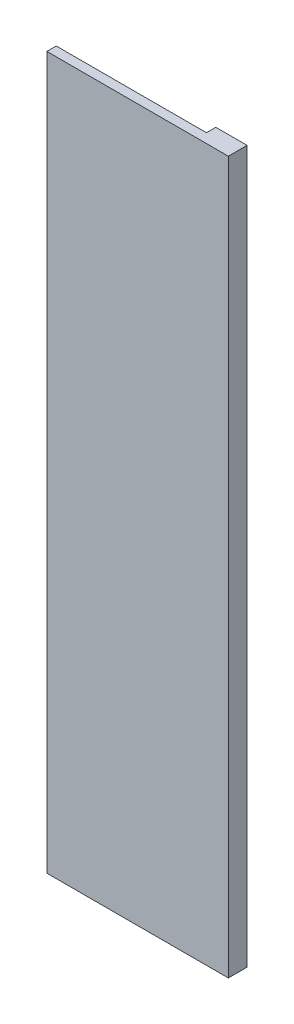
from build123d import *

# Parameters (mm, degrees)
BOSS_EXTRUDE1_DEPTH = 6
SKETCH2_W           = 116
SKETCH2_H           = 455
BOSS_EXTRUDE2_DEPTH = 6
SKETCH3_R           = 10
CUT_EXTRUDE1_DEPTH  = 6


with BuildPart() as part:
    # Sketch1 → Boss-Extrude1 (new body)
    with BuildSketch(Plane.XY):
        Polygon((68, 435), (48, 435), (48, 0), (-48, 0), (-48, -20), (68, -20), align=None)
    extrude(amount=-BOSS_EXTRUDE1_DEPTH)

    # Sketch2 → Boss-Extrude2 (add)
    with BuildSketch(Plane.XY):
        with Locations((10, 207.5)):
            Rectangle(SKETCH2_W, SKETCH2_H)
    extrude(amount=BOSS_EXTRUDE2_DEPTH)

    # Sketch3 → Cut-Extrude1 (cut)
    with BuildSketch(Plane(origin=(0, 0, -6), x_dir=(-1, 0, 0), z_dir=(0, 0, -1))):
        with Locations((-48, 0)):
            Circle(SKETCH3_R)
    extrude(amount=-CUT_EXTRUDE1_DEPTH, mode=Mode.SUBTRACT)


solid = part.part
